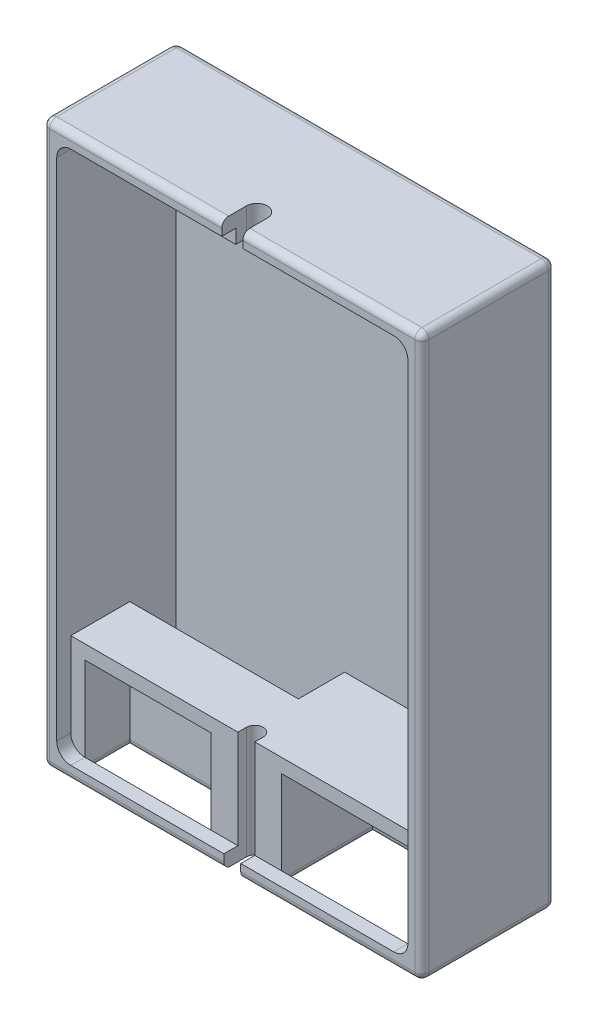
from build123d import *

# Parameters (mm, degrees)
SKETCH_2_W           = 27
SKETCH_2_H           = 40
EXTRUDE_1_DEPTH      = 10
CUT_EXTRUDE_1_DEPTH  = 1.5
CUT_EXTRUDE_2_DEPTH  = 7.5
SKETCH_9_W           = 9
SKETCH_9_H           = 4.718038217
CUT_EXTRUDE_8_DEPTH  = 6.5
SKETCH_9_3_W         = 9
SKETCH_9_3_H         = 4.718038217
CUT_EXTRUDE_9_DEPTH  = 3.2
SKETCH_13_W          = 9
SKETCH_13_H          = 3.2
SKETCH_13_H_2        = 6.5
CUT_EXTRUDE_11_DEPTH = 3.281961783
CUT_EXTRUDE_12_REACH = 42
SKETCH_14_W          = 1.2
SKETCH_14_H          = 2.1
SKETCH_16_2_W        = 7
SKETCH_16_2_H        = 2.5
EXTRUDE_3_DEPTH      = 1
SKETCH_16_W          = 7
SKETCH_16_H          = 2.5
EXTRUDE_2_DEPTH      = 1
CUT_EXTRUDE_14_DEPTH = 2
SKETCH_18_W          = 12
SKETCH_18_H          = 3.3
CUT_EXTRUDE_15_DEPTH = 7
SKETCH_19_W          = 27
SKETCH_19_H          = 40
CUT_EXTRUDE_16_DEPTH = 0.5
FILLET_1_R           = 0.5
FILLET_2_R           = 0.5


with BuildPart() as part:
    # Sketch 2 → Extrude 1 (new body)
    with BuildSketch(Plane.XY):
        with Locations((13.5, 20)):
            Rectangle(SKETCH_2_W, SKETCH_2_H)
    extrude(amount=EXTRUDE_1_DEPTH)

    # Sketch 3 → Cut-Extrude 1 (cut)
    with BuildSketch(Plane.XY.offset(10)):
        with BuildLine():
            Line((1, 38), (1, 2))
            ThreePointArc((1, 2), (1.292893219, 1.292893219), (2, 1))
            Line((2, 1), (25, 1))
            ThreePointArc((25, 1), (25.707106781, 1.292893219), (26, 2))
            Line((26, 2), (26, 38))
            ThreePointArc((26, 38), (25.707106781, 38.707106781), (25, 39))
            Line((25, 39), (2, 39))
            ThreePointArc((2, 39), (1.292893219, 38.707106781), (1, 38))
        make_face()
    extrude(amount=-CUT_EXTRUDE_1_DEPTH, mode=Mode.SUBTRACT)

    # Sketch 5 → Cut-Extrude 2 (cut)
    with BuildSketch(Plane.XY.offset(8.5)):
        with BuildLine():
            Line((2, 39), (25, 39))
            ThreePointArc((25, 39), (25.707106781, 38.707106781), (26, 38))
            Line((26, 38), (26, 8))
            Line((26, 8), (1, 8))
            Line((1, 8), (1, 38))
            ThreePointArc((1, 38), (1.292893219, 38.707106781), (2, 39))
        make_face()
    extrude(amount=-CUT_EXTRUDE_2_DEPTH, mode=Mode.SUBTRACT)

    # Sketch 9 → Cut-Extrude 8 (cut)
    with BuildSketch(Plane.XY.offset(8.5)):
        with Locations((20.5, 4.640980891)):
            Rectangle(SKETCH_9_W, SKETCH_9_H)
    extrude(amount=-CUT_EXTRUDE_8_DEPTH, mode=Mode.SUBTRACT)

    # Sketch 9_3 → Cut-Extrude 9 (cut)
    with BuildSketch(Plane.XY.offset(8.5)):
        with Locations((6.5, 4.640980891)):
            Rectangle(SKETCH_9_3_W, SKETCH_9_3_H)
    extrude(amount=-CUT_EXTRUDE_9_DEPTH, mode=Mode.SUBTRACT)

    # Sketch 13 → Cut-Extrude 11 (cut, through all)
    with BuildSketch(Plane(origin=(0, 2.281961783, 0), x_dir=(1, 0, 0), z_dir=(0, 1, 0))):
        with Locations((6.5, -6.9)):
            Rectangle(SKETCH_13_W, SKETCH_13_H)
        with Locations((20.5, -5.25)):
            Rectangle(SKETCH_13_W, SKETCH_13_H_2)
    extrude(amount=-CUT_EXTRUDE_11_DEPTH, mode=Mode.SUBTRACT)

    # Sketch 14 → Cut-Extrude 12 (cut, up to next)
    with BuildSketch(Plane.XZ, mode=Mode.PRIVATE) as cut_extrude_12_sk1:
        with BuildLine():
            Line((12.9, 7.9), (14.1, 7.9))
            ThreePointArc((14.1, 7.9), (13.5, 7.3), (12.9, 7.9))
        make_face()
    cut_extrude_12_tool1 = extrude(cut_extrude_12_sk1.sketch, amount=-CUT_EXTRUDE_12_REACH, mode=Mode.PRIVATE) & part.part
    add(cut_extrude_12_tool1.solids().sort_by_distance((13.5, 0, 7.645352))[0], mode=Mode.SUBTRACT)
    # Sketch 14 → Cut-Extrude 12 (cut, up to next)
    with BuildSketch(Plane.XZ, mode=Mode.PRIVATE) as cut_extrude_12_sk2:
        with Locations((13.5, 8.95)):
            Rectangle(SKETCH_14_W, SKETCH_14_H)
    cut_extrude_12_tool2 = extrude(cut_extrude_12_sk2.sketch, amount=-CUT_EXTRUDE_12_REACH, mode=Mode.PRIVATE) & part.part
    add(cut_extrude_12_tool2.solids().sort_by_distance((13.5, 0, 8.95))[0], mode=Mode.SUBTRACT)

    # Sketch 16_2 → Extrude 3 (add)
    with BuildSketch(Plane.XZ.offset(-39)):
        with Locations((13.5, 7.25)):
            Rectangle(SKETCH_16_2_W, SKETCH_16_2_H)
    extrude(amount=EXTRUDE_3_DEPTH)

    # Sketch 16 → Extrude 2 (add)
    with BuildSketch(Plane.XZ.offset(-39)):
        with Locations((13.5, 7.25)):
            Rectangle(SKETCH_16_W, SKETCH_16_H)
    extrude(amount=EXTRUDE_2_DEPTH)

    # Sketch 17 → Cut-Extrude 14 (cut)
    with BuildSketch(Plane(origin=(0, 40, 0), x_dir=(1, 0, 0), z_dir=(0, 1, 0))):
        with BuildLine():
            Line((14.25, -7.75), (14.25, -10))
            Line((14.25, -10), (12.75, -10))
            Line((12.75, -10), (12.75, -7.75))
            ThreePointArc((12.75, -7.75), (13.5, -7), (14.25, -7.75))
        make_face()
    extrude(amount=-CUT_EXTRUDE_14_DEPTH, mode=Mode.SUBTRACT)

    # Sketch 18 → Cut-Extrude 15 (cut)
    with BuildSketch(Plane(origin=(0, 8, 0), x_dir=(1, 0, 0), z_dir=(0, 1, 0))):
        with Locations((7, -2.65)):
            Rectangle(SKETCH_18_W, SKETCH_18_H)
    extrude(amount=-CUT_EXTRUDE_15_DEPTH, mode=Mode.SUBTRACT)

    # Sketch 19 → Cut-Extrude 16 (cut)
    with BuildSketch(Plane.XY.offset(10)):
        with Locations((13.5, 20)):
            Rectangle(SKETCH_19_W, SKETCH_19_H)
    extrude(amount=-CUT_EXTRUDE_16_DEPTH, mode=Mode.SUBTRACT)

    # Fillet 1
    fillet_1_edges = [part.edges().sort_by_distance(p)[0] for p in [
        (27, 40, 4.75),
        (0, 40, 4.75),
        (27, 0, 4.75),
        (0, 0, 4.75),
        (20.55, 0, 9.5),
        (20.625, 40, 9.5),
        (6.375, 40, 9.5),
        (0, 20, 9.5),
        (27, 20, 9.5),
        (6.45, 0, 9.5),
        (13.5, 40, 0),
        (27, 20, 0),
        (13.5, 0, 0),
        (0, 20, 0),
    ]]
    fillet(fillet_1_edges, radius=FILLET_1_R)

    # Fillet 2
    fillet_2_edges = [part.edges().sort_by_distance(p)[0] for p in [
        (11, 0, 6.9),
        (2, 0, 6.9),
        (6.5, 0, 5.3),
        (25, 0, 5.25),
        (16, 0, 5.25),
        (20.5, 0, 2),
    ]]
    fillet(fillet_2_edges, radius=FILLET_2_R)


solid = part.part
